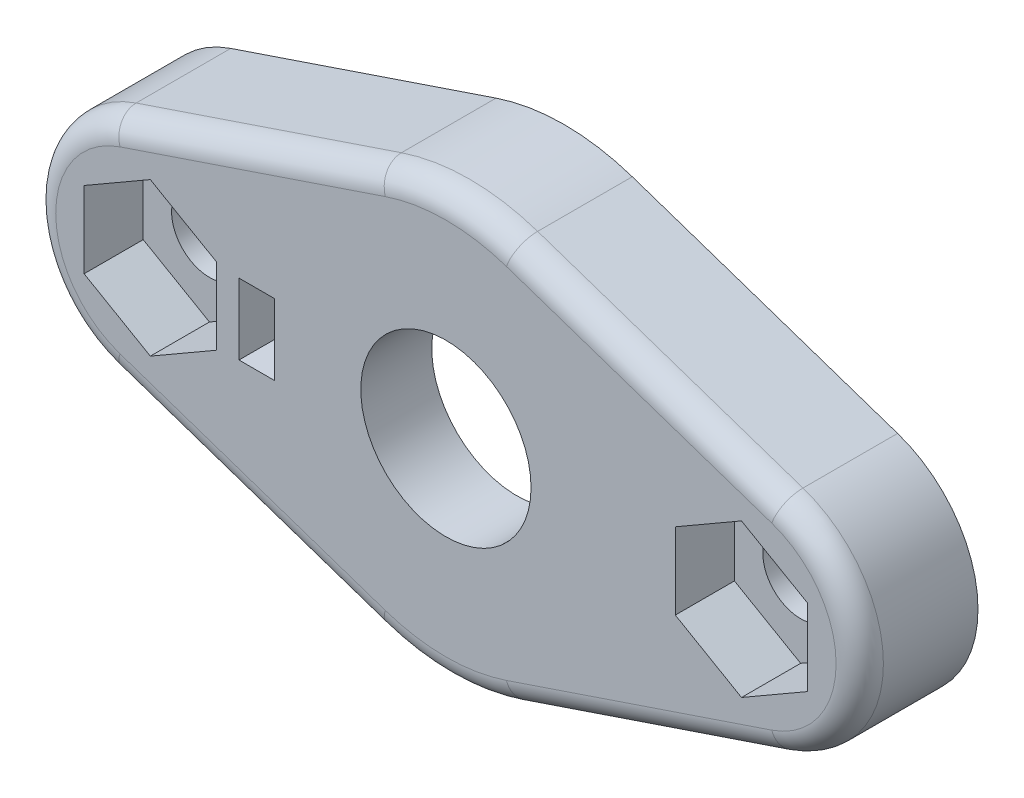
from build123d import *

# Parameters (mm, degrees)
EXTRUDE_1_DEPTH     = 5
SKETCH_1_3_R        = 7.6
CUT_EXTRUDE_1_DEPTH = 2
SKETCH_1_4_R        = 3.6
SKETCH_1_4_R_2      = 1.6
CUT_EXTRUDE_2_DEPTH = 5
CUT_EXTRUDE_START   = 5
SKETCH_1_5_W        = 1.5
SKETCH_1_5_H        = 3
CUT_EXTRUDE_3_DEPTH = 2.5
CUT_EXTRUDE_4_DEPTH = 2.5
FILLET_1_R          = 1


with BuildPart() as part:
    # Эскиз1 → Бобышка-Вытянуть1 (new body)
    with BuildSketch(Plane.XY):
        with BuildLine():
            Line((-14.1, 4.737087713), (-2.88, 8.526757883))
            ThreePointArc((-2.88, 8.526757883), (0, 9), (2.88, 8.526757883))
            Line((2.88, 8.526757883), (14.1, 4.737087713))
            ThreePointArc((14.1, 4.737087713), (17.5, 0), (14.1, -4.737087713))
            Line((14.1, -4.737087713), (2.88, -8.526757883))
            ThreePointArc((2.88, -8.526757883), (0, -9), (-2.88, -8.526757883))
            Line((-2.88, -8.526757883), (-14.1, -4.737087713))
            ThreePointArc((-14.1, -4.737087713), (-17.5, 0), (-14.1, 4.737087713))
        make_face()
    extrude(amount=EXTRUDE_1_DEPTH)

    # Эскиз1<3> → Вырез-Вытянуть1 (cut)
    with BuildSketch(Plane.XY):
        Circle(SKETCH_1_3_R)
    extrude(amount=CUT_EXTRUDE_1_DEPTH, mode=Mode.SUBTRACT)

    # Эскиз1<4> → Вырез-Вытянуть2 (cut)
    with BuildSketch(Plane.XY):
        Circle(SKETCH_1_4_R)
        with Locations((-12.5, 0)):
            Circle(SKETCH_1_4_R_2)
        with Locations((12.5, 0)):
            Circle(SKETCH_1_4_R_2)
    extrude(amount=CUT_EXTRUDE_2_DEPTH, mode=Mode.SUBTRACT)

    # Эскиз1<5> → Вырез-Вытянуть3 (cut)
    with BuildSketch(Plane.XY.offset(CUT_EXTRUDE_START)):
        with Locations((-8, 0)):
            Rectangle(SKETCH_1_5_W, SKETCH_1_5_H)
    extrude(amount=-CUT_EXTRUDE_3_DEPTH, mode=Mode.SUBTRACT)

    # Эскиз2 → Вырез-Вытянуть4 (cut)
    with BuildSketch(Plane.XY.offset(5)):
        Polygon((-12.5, 3.233161507), (-15.3, 1.616580754), (-15.3, -1.616580754), (-12.5, -3.233161507), (-9.7, -1.616580754), (-9.7, 1.616580754), align=None)
        Polygon((12.5, 3.233161507), (9.7, 1.616580754), (9.7, -1.616580754), (12.5, -3.233161507), (15.3, -1.616580754), (15.3, 1.616580754), align=None)
    extrude(amount=-CUT_EXTRUDE_4_DEPTH, mode=Mode.SUBTRACT)

    # Скругление1
    fillet_1_edges = [part.edges().sort_by_distance(p)[0] for p in [
        (0, -9, 5),
        (-8.49, -6.631922798, 5),
        (-17.5, 0, 5),
        (-8.49, 6.631922798, 5),
        (0, 9, 5),
        (8.49, 6.631922798, 5),
        (17.5, 0, 5),
        (8.49, -6.631922798, 5),
    ]]
    fillet(fillet_1_edges, radius=FILLET_1_R)


solid = part.part
